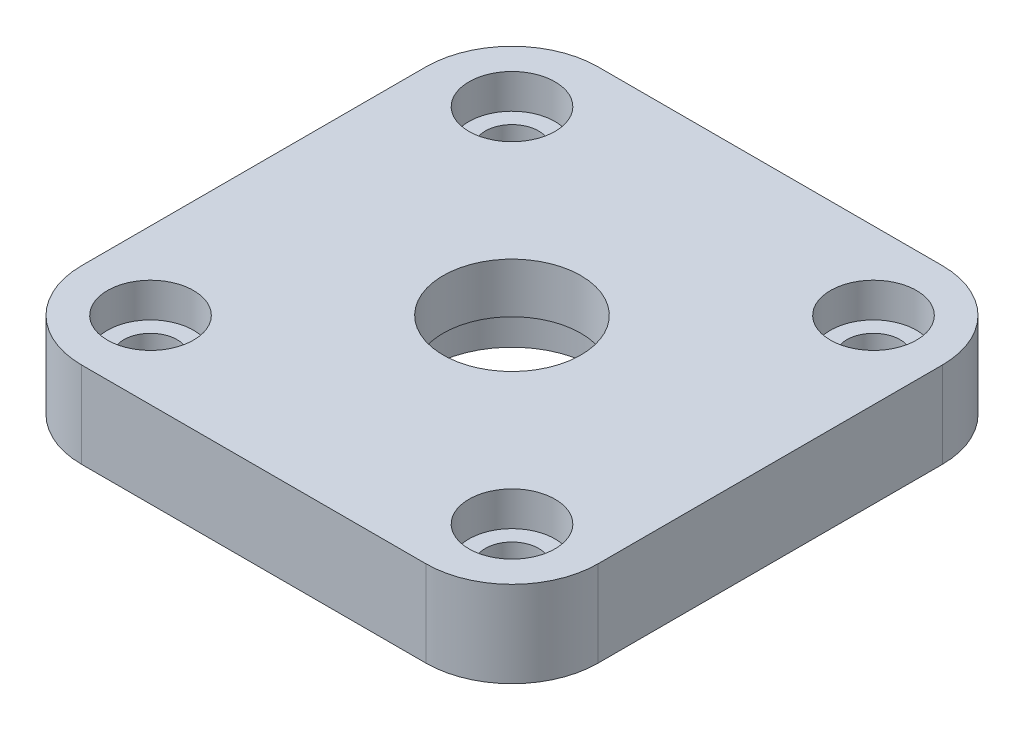
from build123d import *

# Parameters (mm, degrees)
SKETCH1_W               = 30
SKETCH1_H               = 30
BOSS_EXTRUDE1_DEPTH     = 5
SKETCH2_R               = 4
CUT_EXTRUDE1_DEPTH      = 1
CUT_EXTRUDE1_DEPTH_BACK = 6
SKETCH3_R               = 1.55
CUT_EXTRUDE2_DEPTH      = 1
CUT_EXTRUDE2_DEPTH_BACK = 6
SKETCH4_R               = 4.8
CUT_EXTRUDE3_DEPTH      = 2.1
FILLET1_R               = 5
SKETCH5_R               = 2.5
CUT_EXTRUDE4_DEPTH      = 2


with BuildPart() as part:
    # Sketch1 → Boss-Extrude1 (new body)
    with BuildSketch(Plane(origin=(0, 0, 0), x_dir=(1, 0, 0), z_dir=(0, 1, 0))):
        Rectangle(SKETCH1_W, SKETCH1_H)
    extrude(amount=BOSS_EXTRUDE1_DEPTH)

    # Sketch2 → Cut-Extrude1 (cut, two sides)
    with BuildSketch(Plane(origin=(0, 5, 0), x_dir=(1, 0, 0), z_dir=(0, 1, 0))) as cut_extrude1_sk:
        Circle(SKETCH2_R)
    extrude(amount=CUT_EXTRUDE1_DEPTH, mode=Mode.SUBTRACT)
    extrude(cut_extrude1_sk.sketch, amount=-CUT_EXTRUDE1_DEPTH_BACK, mode=Mode.SUBTRACT)

    # Sketch3 → Cut-Extrude2 (cut, two sides)
    with BuildSketch(Plane(origin=(0, 5, 0), x_dir=(1, 0, 0), z_dir=(0, 1, 0))) as cut_extrude2_sk:
        with Locations((-10.5, 10.5)):
            Circle(SKETCH3_R)
        with Locations((10.5, 10.5)):
            Circle(SKETCH3_R)
        with Locations((10.5, -10.5)):
            Circle(SKETCH3_R)
        with Locations((-10.5, -10.5)):
            Circle(SKETCH3_R)
    extrude(amount=CUT_EXTRUDE2_DEPTH, mode=Mode.SUBTRACT)
    extrude(cut_extrude2_sk.sketch, amount=-CUT_EXTRUDE2_DEPTH_BACK, mode=Mode.SUBTRACT)

    # Sketch4 → Cut-Extrude3 (cut)
    with BuildSketch(Plane.XZ):
        Circle(SKETCH4_R)
    extrude(amount=-CUT_EXTRUDE3_DEPTH, mode=Mode.SUBTRACT)

    # Fillet1
    fillet1_edges = [part.edges().sort_by_distance(p)[0] for p in [
        (15, 2.5, 15),
        (-15, 2.5, 15),
        (-15, 2.5, -15),
        (15, 2.5, -15),
    ]]
    fillet(fillet1_edges, radius=FILLET1_R)

    # Sketch5 → Cut-Extrude4 (cut)
    with BuildSketch(Plane(origin=(0, 5, 0), x_dir=(1, 0, 0), z_dir=(0, 1, 0))):
        with Locations((-10.5, 10.5)):
            Circle(SKETCH5_R)
        with Locations((10.5, 10.5)):
            Circle(SKETCH5_R)
        with Locations((-10.5, -10.5)):
            Circle(SKETCH5_R)
        with Locations((10.5, -10.5)):
            Circle(SKETCH5_R)
    extrude(amount=-CUT_EXTRUDE4_DEPTH, mode=Mode.SUBTRACT)


solid = part.part
